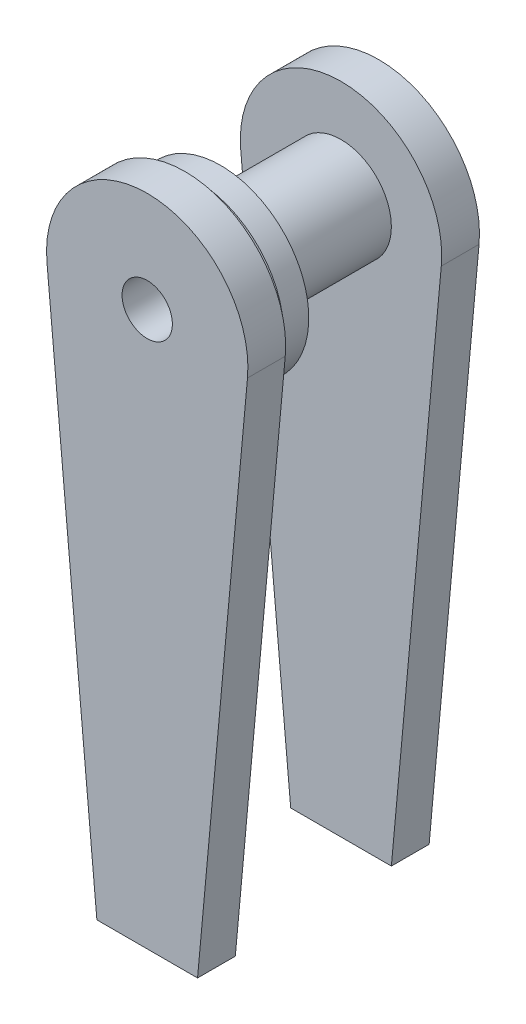
from build123d import *

# Parameters (mm, degrees)
SKETCH1_R           = 25.4
SKETCH1_R_2         = 6.35
BOSS_EXTRUDE1_DEPTH = 9.525
SKETCH2_R           = 12.7
SKETCH2_R_2         = 6.35
BOSS_EXTRUDE2_DEPTH = 39.37
SKETCH3_R           = 22.225
SKETCH3_R_2         = 12.7
BOSS_EXTRUDE3_DEPTH = 6.35


with BuildPart() as part:
    # Sketch1 → Boss-Extrude1 (new body)
    with BuildSketch(Plane.XY):
        with BuildLine():
            ThreePointArc((25.293941551, -2.318732586), (0, -25.4), (-25.293941551, -2.318732586))
            Line((-25.293941551, -2.318732586), (-12.7, -139.7))
            Line((-12.7, -139.7), (12.7, -139.7))
            Line((12.7, -139.7), (25.293941551, -2.318732586))
        make_face()
        Circle(SKETCH1_R)
        Circle(SKETCH1_R_2, mode=Mode.SUBTRACT)
    boss_extrude1 = extrude(amount=BOSS_EXTRUDE1_DEPTH)

    # Sketch2 → Boss-Extrude2 (add)
    with BuildSketch(Plane.XY.offset(9.525)):
        Circle(SKETCH2_R)
        Circle(SKETCH2_R_2, mode=Mode.SUBTRACT)
    extrude(amount=BOSS_EXTRUDE2_DEPTH)

    # Mirror2: Boss-Extrude1 across plane
    add(boss_extrude1.mirror(Plane(origin=(0, 0, 29.21), x_dir=(1, 0, 0), z_dir=(0, 0, -1))))

    # Sketch3 → Boss-Extrude3 (add)
    with BuildSketch(Plane(origin=(0, 0, 39.878), x_dir=(-1, 0, 0), z_dir=(0, 0, -1))):
        Circle(SKETCH3_R)
        Circle(SKETCH3_R_2, mode=Mode.SUBTRACT)
    extrude(amount=-BOSS_EXTRUDE3_DEPTH)


solid = part.part
